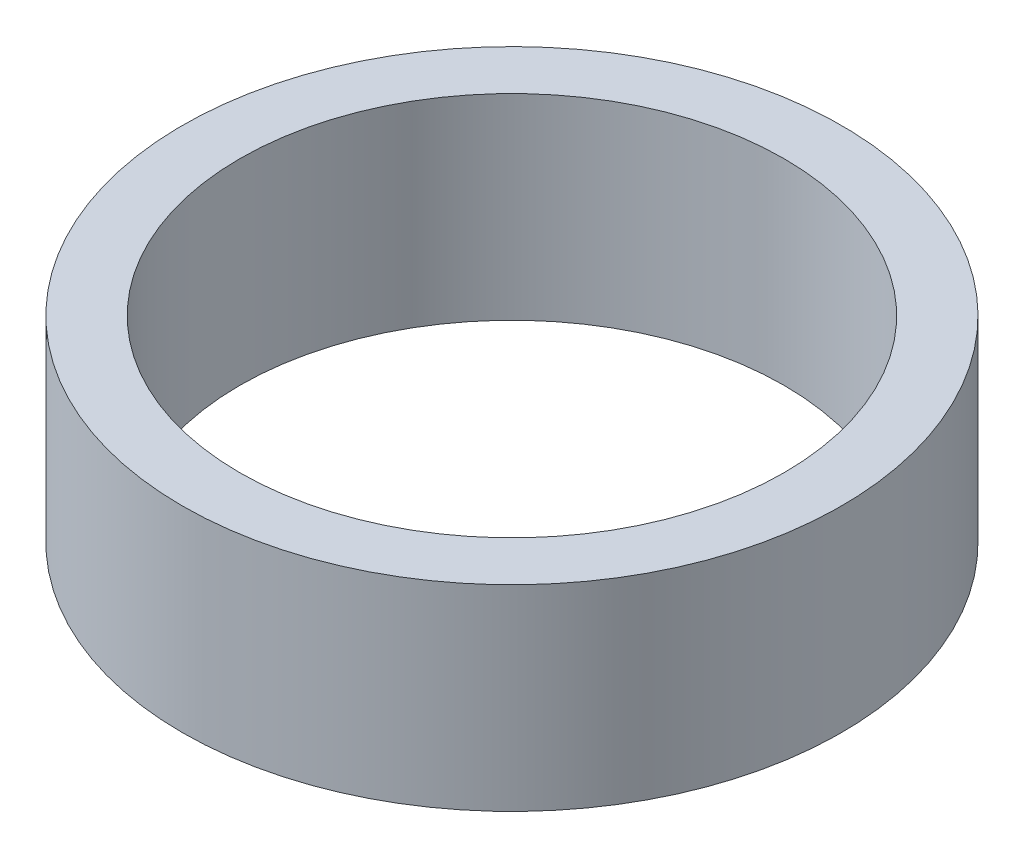
from build123d import *

# Parameters (mm, degrees)
SKETCH1_R           = 23.5
SKETCH1_R_2         = 19.4
BOSS_EXTRUDE1_DEPTH = 14


with BuildPart() as part:
    # Sketch1 → Boss-Extrude1 (new body)
    with BuildSketch(Plane(origin=(0, 0, 0), x_dir=(1, 0, 0), z_dir=(0, 1, 0))):
        Circle(SKETCH1_R)
        Circle(SKETCH1_R_2, mode=Mode.SUBTRACT)
    extrude(amount=BOSS_EXTRUDE1_DEPTH)


solid = part.part
